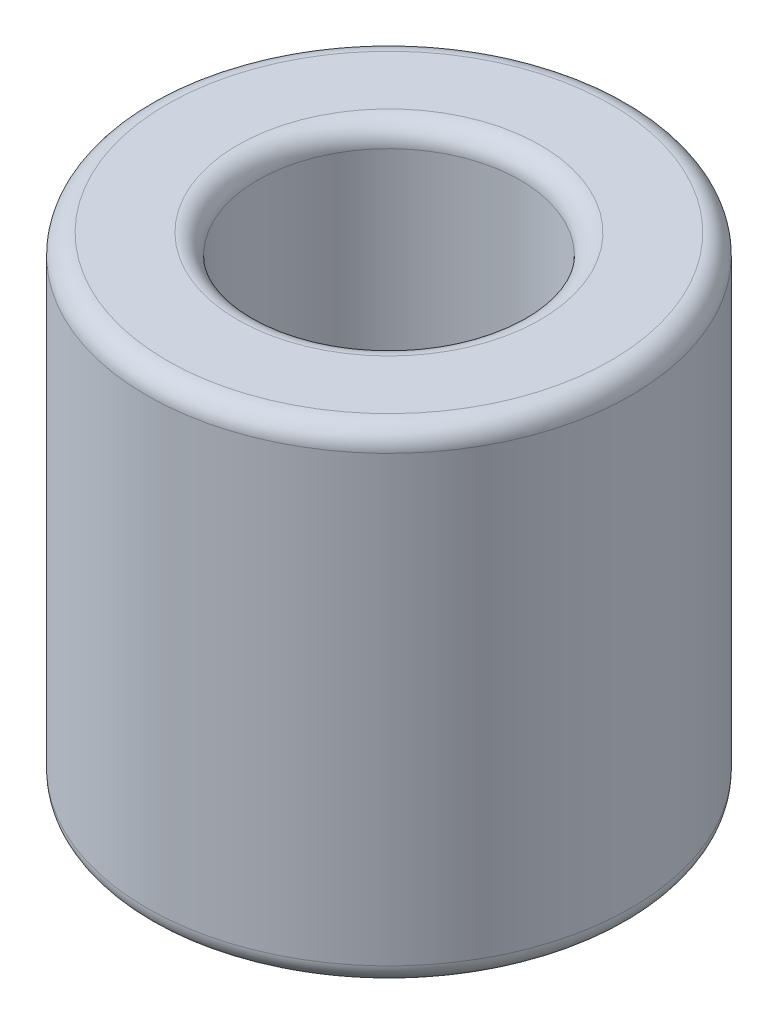
from build123d import *

# Parameters (mm, degrees)
SKETCH1_R           = 3
SKETCH1_R_2         = 1.625
BOSS_EXTRUDE1_DEPTH = 6
FILLET1_R           = 0.25


with BuildPart() as part:
    # Sketch1 → Boss-Extrude1 (new body)
    with BuildSketch(Plane(origin=(0, 0, 0), x_dir=(1, 0, 0), z_dir=(0, 1, 0))):
        with Locations(Location((0, 0, 0), (0, 0, 270))):  # turned: the seam where the file's is
            Circle(SKETCH1_R)
        with Locations(Location((0, 0, 0), (0, 0, 270))):  # turned: the seam where the file's is
            Circle(SKETCH1_R_2, mode=Mode.SUBTRACT)
    extrude(amount=BOSS_EXTRUDE1_DEPTH)

    # Fillet1
    fillet1_edges = [part.edges().sort_by_distance(p)[0] for p in [
        (0, 0, -3),
        (0, 6, -3),
        (0, 0, -1.625),
        (0, 6, -1.625),
    ]]
    fillet(fillet1_edges, radius=FILLET1_R)


solid = part.part
